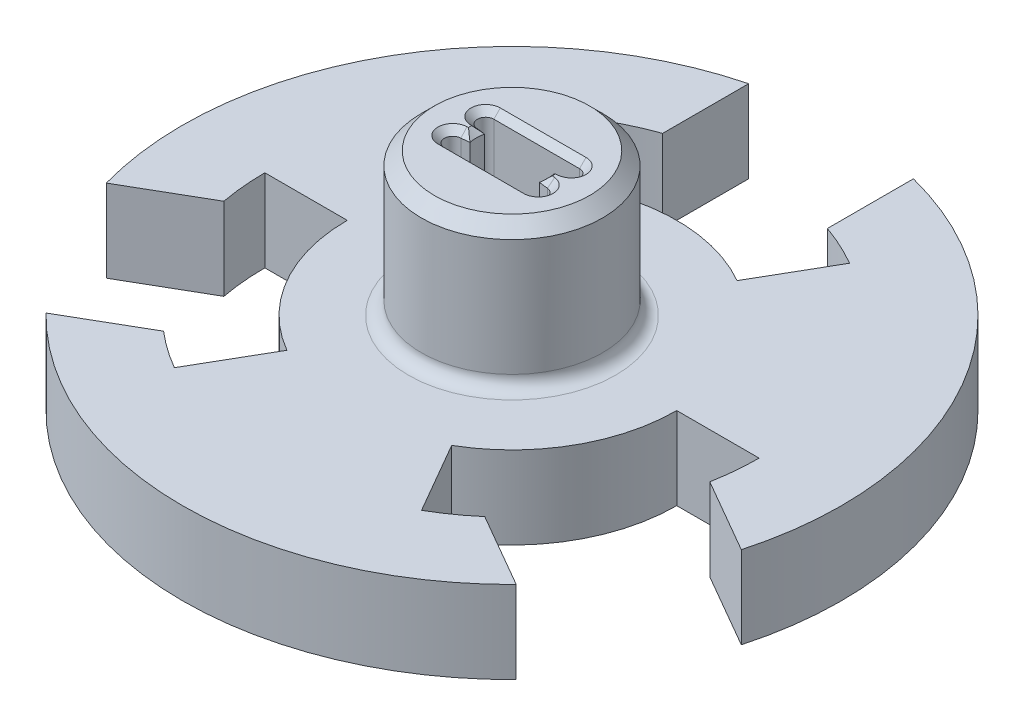
from build123d import *

# Parameters (mm, degrees)
SKETCH1_R           = 6.985
BOSS_EXTRUDE1_DEPTH = 10.9965998
CHAMFER5_SIZE       = 1
CHAMFER6_SIZE       = 0.500000016
SKETCH2_R           = 1.058078275
BOSS_EXTRUDE2_DEPTH = 6.35
FILLET1_R           = 1.000000032
SKETCH3_R           = 1.905
CUT_EXTRUDE1_DEPTH  = 2.54


with BuildPart() as part:
    # Sketch1 → Boss-Extrude1 (new body)
    with BuildSketch(Plane(origin=(0, 0, 0), x_dir=(1, 0, 0), z_dir=(0, 1, 0))):
        Circle(SKETCH1_R)
        with BuildLine():
            Line((-3.302, 1.905), (3.302, 1.905))
            ThreePointArc((3.302, 1.905), (3.937, 1.27), (3.302, 0.635))
            Line((3.302, 0.635), (2.67270889, 0.5588))
            ThreePointArc((2.67270889, 0.5588), (2.7305, 0), (2.67270889, -0.5588))
            Line((2.67270889, -0.5588), (3.374233059, -0.639121735))
            ThreePointArc((3.374233059, -0.639121735), (3.935968729, -1.30617528), (3.302, -1.905))
            Line((3.302, -1.905), (-3.302, -1.905))
            ThreePointArc((-3.302, -1.905), (-3.937, -1.27), (-3.302, -0.635))
            Line((-3.302, -0.635), (-2.67270889, -0.5588))
            ThreePointArc((-2.67270889, -0.5588), (-2.7305, 0), (-2.67270889, 0.5588))
            Line((-2.67270889, 0.5588), (-3.374233059, 0.639121735))
            ThreePointArc((-3.374233059, 0.639121735), (-3.935968729, 1.30617528), (-3.302, 1.905))
        make_face(mode=Mode.SUBTRACT)
    extrude(amount=BOSS_EXTRUDE1_DEPTH)

    # Chamfer5
    chamfer5_edges = [part.edges().sort_by_distance(p)[0] for p in [
        (-6.985, 10.9965998, 0),
    ]]
    chamfer(chamfer5_edges, length=CHAMFER5_SIZE)

    # Chamfer6
    chamfer6_edges = [part.edges().sort_by_distance(p)[0] for p in [
        (-2.7305, 10.9965998, 0),
        (-2.987354445, 10.9965998, 0.5969),
        (-3.937, 10.9965998, 1.27),
        (0, 10.9965998, 1.905),
        (3.935968729, 10.9965998, 1.30617528),
        (3.023470975, 10.9965998, 0.598960868),
        (2.7305, 10.9965998, 0),
        (2.987354445, 10.9965998, -0.5969),
        (3.937, 10.9965998, -1.27),
        (0, 10.9965998, -1.905),
        (-3.935968729, 10.9965998, -1.30617528),
        (-3.023470975, 10.9965998, -0.598960868),
    ]]
    chamfer(chamfer6_edges, length=CHAMFER6_SIZE)

    # Sketch2 → Boss-Extrude2 (add)
    with BuildSketch(Plane.XZ):
        with BuildLine():
            Line((-6.35, -24.593444248), (-6.35, -17.960512242))
            ThreePointArc((-6.35, -17.960512242), (-7.971122868, -17.302129933), (-9.525, -16.497783942))
            Line((-9.525, -16.497783942), (-6.35, -10.998522628))
            ThreePointArc((-6.35, -10.998522628), (0, -12.7), (6.35, -10.998522628))
            Line((6.35, -10.998522628), (9.525, -16.497783942))
            ThreePointArc((9.525, -16.497783942), (7.971122868, -17.302129933), (6.35, -17.960512242))
            Line((6.35, -17.960512242), (6.35, -24.593444248))
            ThreePointArc((6.35, -24.593444248), (21.997045256, -12.7), (24.473547486, 6.79746081))
            Line((24.473547486, 6.79746081), (18.729259867, 3.480994807))
            ThreePointArc((18.729259867, 3.480994807), (18.969645496, 1.747870067), (19.05, 0))
            Line((19.05, 0), (12.7, 0))
            ThreePointArc((12.7, 0), (10.998522628, 6.35), (6.35, 10.998522628))
            Line((6.35, 10.998522628), (9.525, 16.497783942))
            ThreePointArc((9.525, 16.497783942), (10.998522628, 15.554259867), (12.379259867, 14.479517435))
            Line((12.379259867, 14.479517435), (18.123547486, 17.795983438))
            ThreePointArc((18.123547486, 17.795983438), (0, 25.4), (-18.123547486, 17.795983438))
            Line((-18.123547486, 17.795983438), (-12.379259867, 14.479517435))
            ThreePointArc((-12.379259867, 14.479517435), (-10.998522628, 15.554259867), (-9.525, 16.497783942))
            Line((-9.525, 16.497783942), (-6.35, 10.998522628))
            ThreePointArc((-6.35, 10.998522628), (-10.998522628, 6.35), (-12.7, 0))
            Line((-12.7, 0), (-19.05, 0))
            ThreePointArc((-19.05, 0), (-18.969645496, 1.747870067), (-18.729259867, 3.480994807))
            Line((-18.729259867, 3.480994807), (-24.473547486, 6.79746081))
            ThreePointArc((-24.473547486, 6.79746081), (-21.997045256, -12.7), (-6.35, -24.593444248))
        make_face()
        Circle(SKETCH2_R, mode=Mode.SUBTRACT)
    extrude(amount=BOSS_EXTRUDE2_DEPTH)

    # Fillet1
    fillet1_edges = [part.edges().sort_by_distance(p)[0] for p in [
        (-6.985, 0, 0),
    ]]
    fillet(fillet1_edges, radius=FILLET1_R)

    # Sketch3 → Cut-Extrude1 (cut)
    with BuildSketch(Plane.XZ.offset(6.35)):
        Circle(SKETCH3_R)
    extrude(amount=-CUT_EXTRUDE1_DEPTH, mode=Mode.SUBTRACT)


solid = part.part
